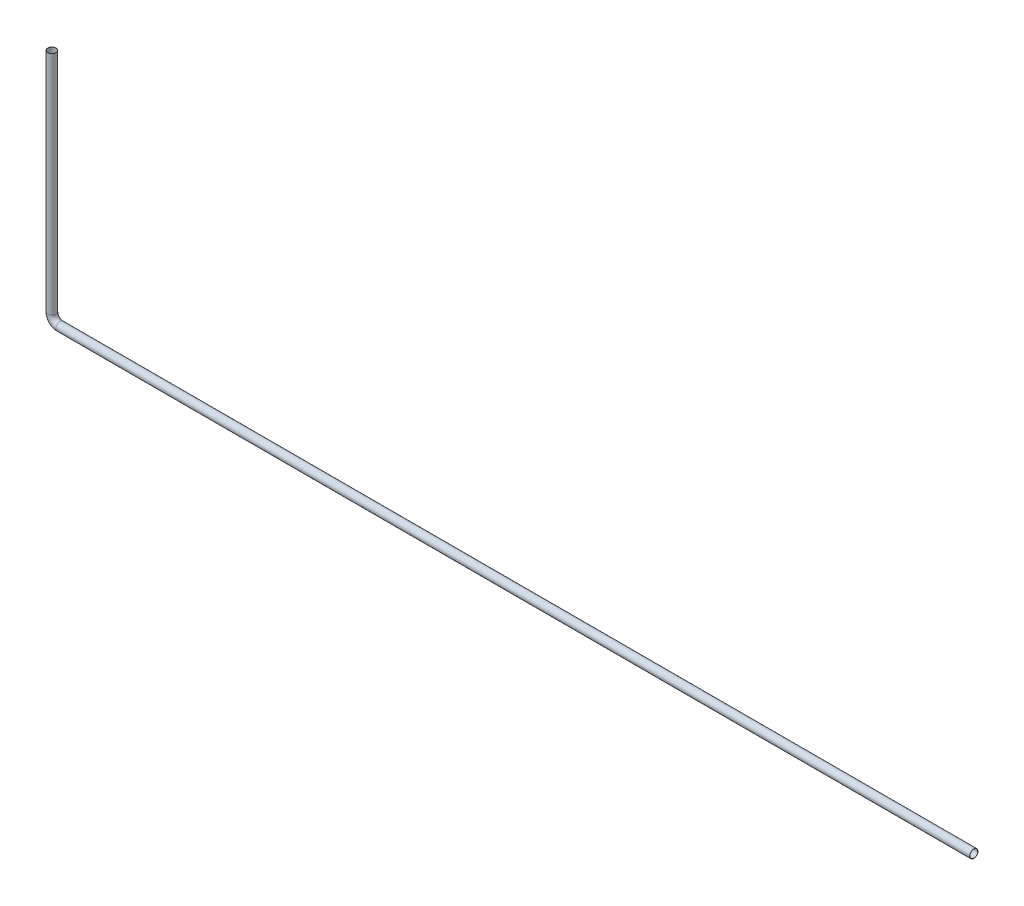
from build123d import *

# Parameters (mm, degrees)
SWEEP_THIN1_PROFILE_R   = 15
SWEEP_THIN1_PROFILE_R_2 = 14


with BuildPart() as part:
    # Sweep-Thin1: sweep along a curve in space
    with BuildLine() as sweep_thin1_path:
        Line((-31937.449283249, -17211.178360788, 41573.160381203), (-31937.449283249, -18029.171841759, 41573.160381203))
        ThreePointArc((-31907.449283249, -18059.171841759, 41573.160381203), (-31928.662486685, -18050.385045195, 41573.160381203), (-31937.449283249, -18029.171841759, 41573.160381203))
        Line((-31907.449283249, -18059.171841759, 41573.160381203), (-28606.329730851, -18059.171841759, 41573.160381203))
    # Sweep-Thin1 profile (on start of the path) → Sweep-Thin1 (sweep)
    with BuildSketch(Plane(origin=(-31937.449283249, -17211.178360788, 41573.160381203), x_dir=(0, 0, -1), z_dir=(0, -1, 0))):
        Circle(SWEEP_THIN1_PROFILE_R)
        Circle(SWEEP_THIN1_PROFILE_R_2, mode=Mode.SUBTRACT)
    sweep(path=sweep_thin1_path.line)


solid = part.part
